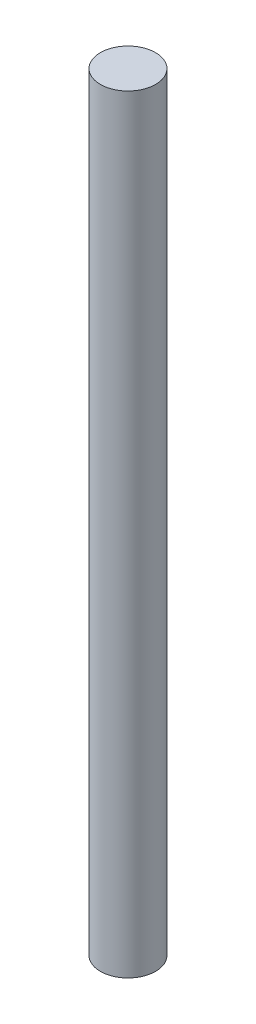
from build123d import *

# Parameters (mm, degrees)
SKETCH1_R           = 4
BOSS_EXTRUDE1_DEPTH = 55.7


with BuildPart() as part:
    # Sketch1 → Boss-Extrude1 (new body, symmetric)
    with BuildSketch(Plane(origin=(0, 0, 0), x_dir=(1, 0, 0), z_dir=(0, 1, 0))):
        Circle(SKETCH1_R)
    extrude(amount=BOSS_EXTRUDE1_DEPTH, both=True)


solid = part.part
